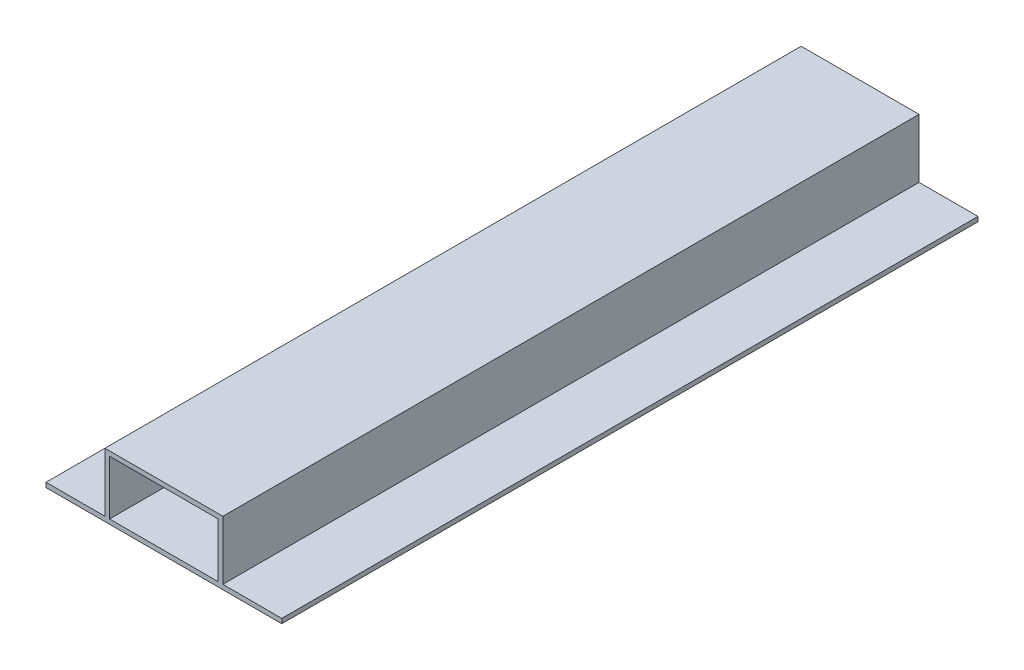
from build123d import *

# Parameters (mm, degrees)
SALIENTE_EXTRUIR1_DEPTH = 75


with BuildPart() as part:
    # Croquis1 → Saliente-Extruir1 (new body, symmetric)
    with BuildSketch(Plane.XY):
        Polygon((0, 13.7), (12.7, 13.7), (12.7, 1), (25.4, 1), (25.4, 0), (-25.4, 0), (-25.4, 1), (-12.7, 1), (-12.7, 13.7), align=None)
        Polygon((0, 12.7), (-11.7, 12.7), (-11.7, 1), (11.7, 1), (11.7, 12.7), align=None, mode=Mode.SUBTRACT)
    extrude(amount=SALIENTE_EXTRUIR1_DEPTH, both=True)


solid = part.part
